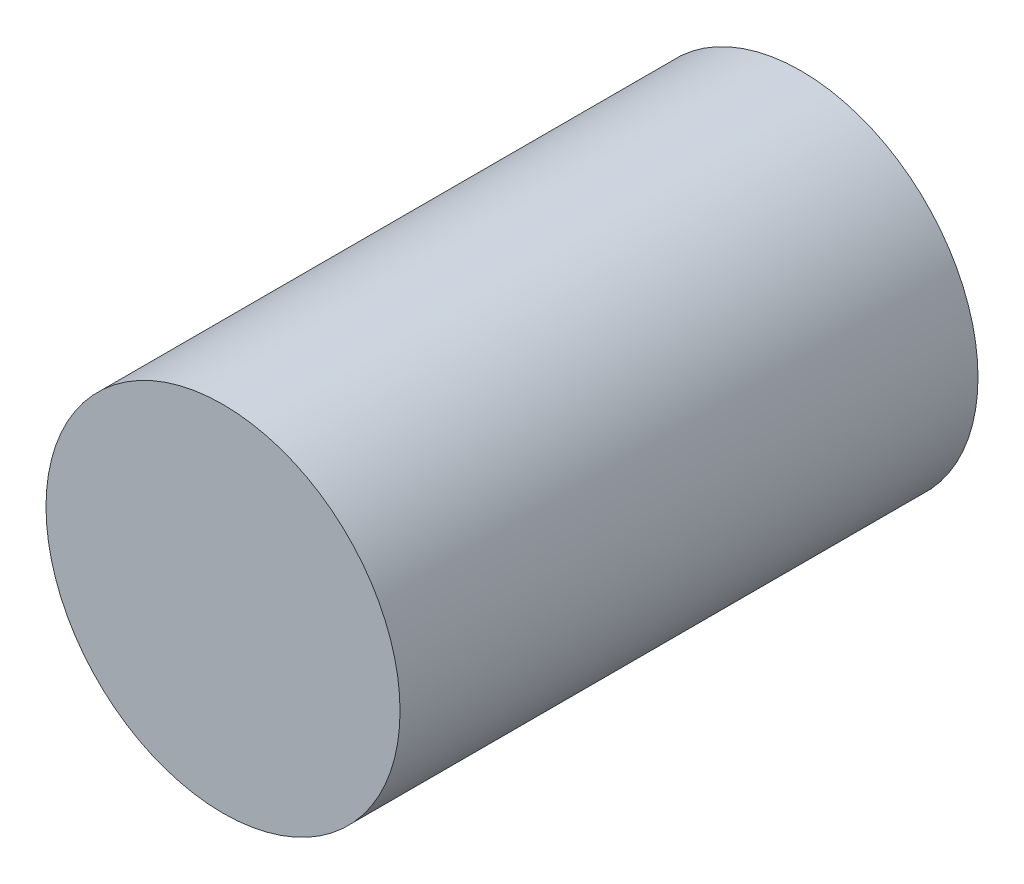
from build123d import *

# Parameters (mm, degrees)
SKETCH2_R                = 6.425
BOSS_EXTRUDE1_DEPTH      = 6.45
BOSS_EXTRUDE1_DEPTH_BACK = 14.527149266


with BuildPart() as part:
    # Sketch2 → Boss-Extrude1 (new body, two sides)
    with BuildSketch(Plane.XY) as boss_extrude1_sk:
        with Locations((15, 15)):
            Circle(SKETCH2_R)
    extrude(amount=BOSS_EXTRUDE1_DEPTH)
    extrude(boss_extrude1_sk.sketch, amount=-BOSS_EXTRUDE1_DEPTH_BACK)


solid = part.part
